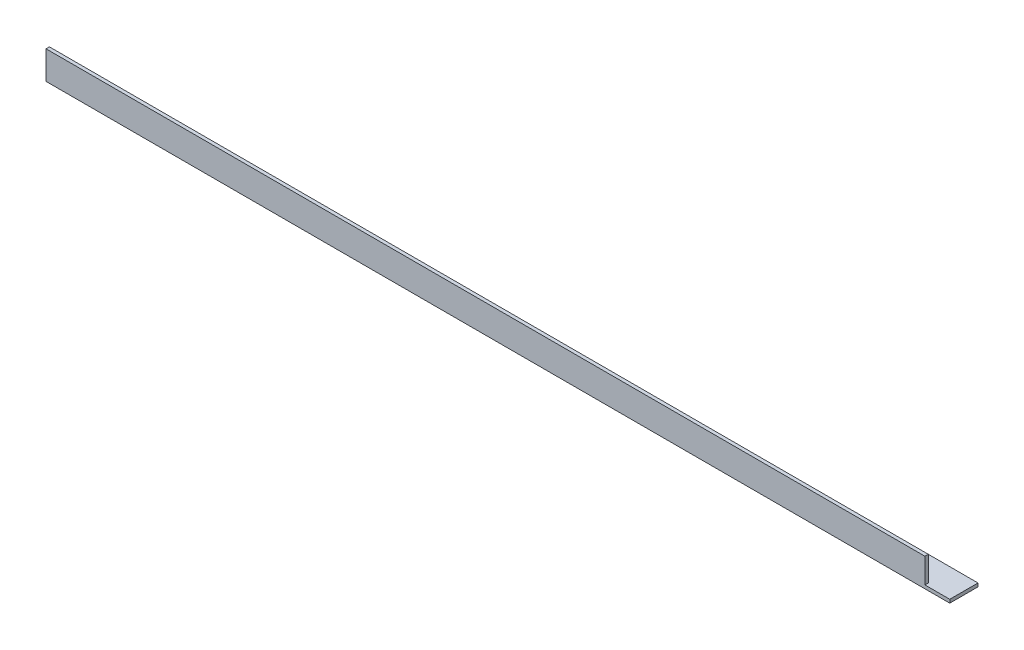
from build123d import *

# Parameters (mm, degrees)
EXTRUDE_1_DEPTH     = 800
CUT_EXTRUDE_1_REACH = 27
SKETCH_2_W          = 22
SKETCH_2_H          = 22


with BuildPart() as part:
    # Эскиз1 → Вытянуть-Тонкостенный1 (new body)
    with BuildSketch(Plane(origin=(0, 0, 0), x_dir=(0, 0, -1), z_dir=(1, 0, 0))):
        Polygon((0, 25), (0, 0), (25, 0), (25, 3), (3, 3), (3, 25), align=None)
    extrude(amount=EXTRUDE_1_DEPTH)

    # Эскиз2 → Вырез-Вытянуть1 (cut, up to next)
    with BuildSketch(Plane.XY, mode=Mode.PRIVATE) as cut_extrude_1_sk1:
        with Locations((789, 14)):
            Rectangle(SKETCH_2_W, SKETCH_2_H)
    cut_extrude_1_tool1 = extrude(cut_extrude_1_sk1.sketch, amount=-CUT_EXTRUDE_1_REACH, mode=Mode.PRIVATE) & part.part
    add(cut_extrude_1_tool1.solids().sort_by_distance((789, 14, 0))[0], mode=Mode.SUBTRACT)


solid = part.part
